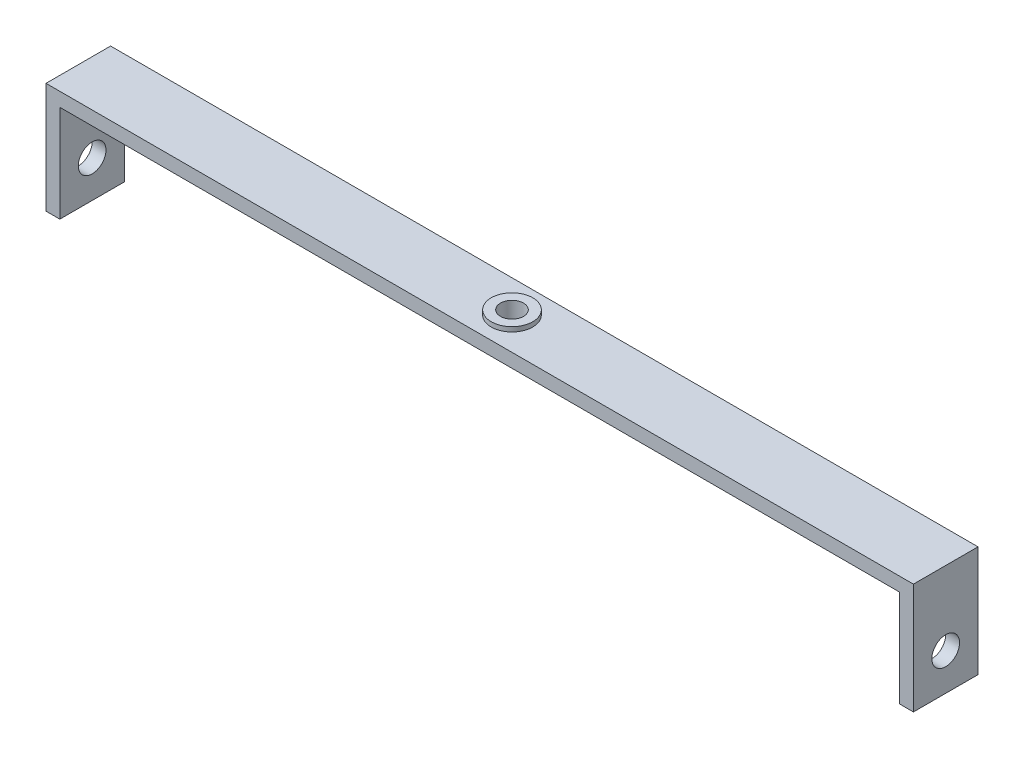
from build123d import *

# Parameters (mm, degrees)
BOSS_EXTRUDE3_DEPTH      = 3.5
BOSS_EXTRUDE3_DEPTH_BACK = 3.5
SKETCH4_R                = 1.25
CUT_EXTRUDE1_DEPTH       = 3.5
SKETCH5_R                = 2.25
SKETCH5_R_2              = 1.25
BOSS_EXTRUDE5_DEPTH      = 0.5
SKETCH8_R                = 1.5
CUT_EXTRUDE3_DEPTH       = 47
SKETCH10_R               = 1.5
CUT_EXTRUDE4_DEPTH       = 47


with BuildPart() as part:
    # Sketch1 → Boss-Extrude3 (new body, two sides)
    with BuildSketch(Plane.XY) as boss_extrude3_sk:
        Polygon((-47, 0), (47, 0), (47, -12), (46.584070796, -12), (45.5, -12), (45.5, -1.5), (-45.5, -1.5), (-45.5, -12), (-47, -12), align=None)
    extrude(amount=BOSS_EXTRUDE3_DEPTH)
    extrude(boss_extrude3_sk.sketch, amount=-BOSS_EXTRUDE3_DEPTH_BACK)

    # Sketch4 → Cut-Extrude1 (cut)
    with BuildSketch(Plane(origin=(0, 0, 0), x_dir=(1, 0, 0), z_dir=(0, 1, 0))):
        Circle(SKETCH4_R)
    extrude(amount=-CUT_EXTRUDE1_DEPTH, mode=Mode.SUBTRACT)

    # Sketch5 → Boss-Extrude5 (add)
    with BuildSketch(Plane(origin=(0, 0, 0), x_dir=(1, 0, 0), z_dir=(0, 1, 0))):
        Circle(SKETCH5_R)
        Circle(SKETCH5_R_2, mode=Mode.SUBTRACT)
    extrude(amount=BOSS_EXTRUDE5_DEPTH)

    # Sketch8 → Cut-Extrude3 (cut)
    with BuildSketch(Plane(origin=(0, 0, 0), x_dir=(0, 0, -1), z_dir=(1, 0, 0))):
        with Locations((0, -8)):
            Circle(SKETCH8_R)
    extrude(amount=CUT_EXTRUDE3_DEPTH, mode=Mode.SUBTRACT)

    # Sketch10 → Cut-Extrude4 (cut)
    with BuildSketch(Plane(origin=(0, 0, 0), x_dir=(0, 0, -1), z_dir=(1, 0, 0))):
        with Locations((0, -8)):
            Circle(SKETCH10_R)
    extrude(amount=-CUT_EXTRUDE4_DEPTH, mode=Mode.SUBTRACT)


solid = part.part
